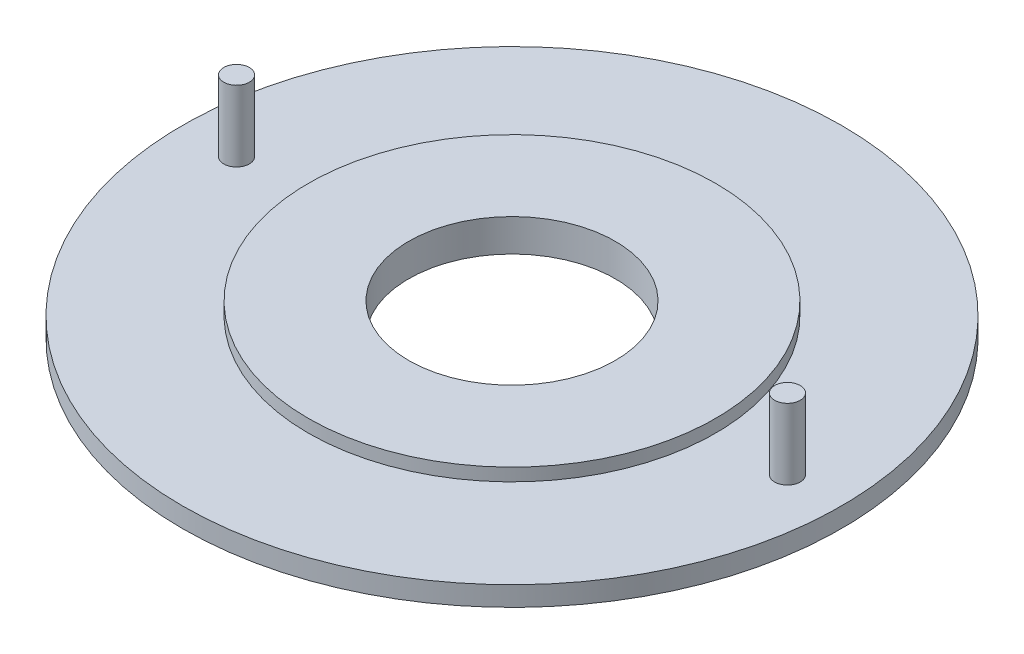
from build123d import *

# Parameters (mm, degrees)
SKETCH_1_R          = 16.75
EXTRUDE_1_DEPTH     = 1
SKETCH_2_R          = 10.35
EXTRUDE_2_DEPTH     = 0.65
SKETCH_3_R          = 5.25
CUT_EXTRUDE_1_DEPTH = 2.65
SKETCH_4_R          = 0.6499985
EXTRUDE_3_DEPTH     = 3.6


with BuildPart() as part:
    # Эскиз1 → Бобышка-Вытянуть1 (new body)
    with BuildSketch(Plane(origin=(0, 0, 0), x_dir=(1, 0, 0), z_dir=(0, 1, 0))):
        Circle(SKETCH_1_R)
    extrude(amount=EXTRUDE_1_DEPTH)

    # Эскиз2 → Бобышка-Вытянуть2 (add)
    with BuildSketch(Plane(origin=(0, 1, 0), x_dir=(1, 0, 0), z_dir=(0, 1, 0))):
        Circle(SKETCH_2_R)
    extrude(amount=EXTRUDE_2_DEPTH)

    # Эскиз3 → Вырез-Вытянуть1 (cut, through all)
    with BuildSketch(Plane(origin=(0, 1.65, 0), x_dir=(1, 0, 0), z_dir=(0, 1, 0))):
        Circle(SKETCH_3_R)
    extrude(amount=-CUT_EXTRUDE_1_DEPTH, mode=Mode.SUBTRACT)

    # Эскиз4 → Бобышка-Вытянуть3 (add)
    with BuildSketch(Plane(origin=(0, 1, 0), x_dir=(1, 0, 0), z_dir=(0, 1, 0))):
        with Locations((14.0000228, 0)):
            Circle(SKETCH_4_R)
        with Locations((-13.999972, 0)):
            Circle(SKETCH_4_R)
    extrude(amount=EXTRUDE_3_DEPTH)


solid = part.part
